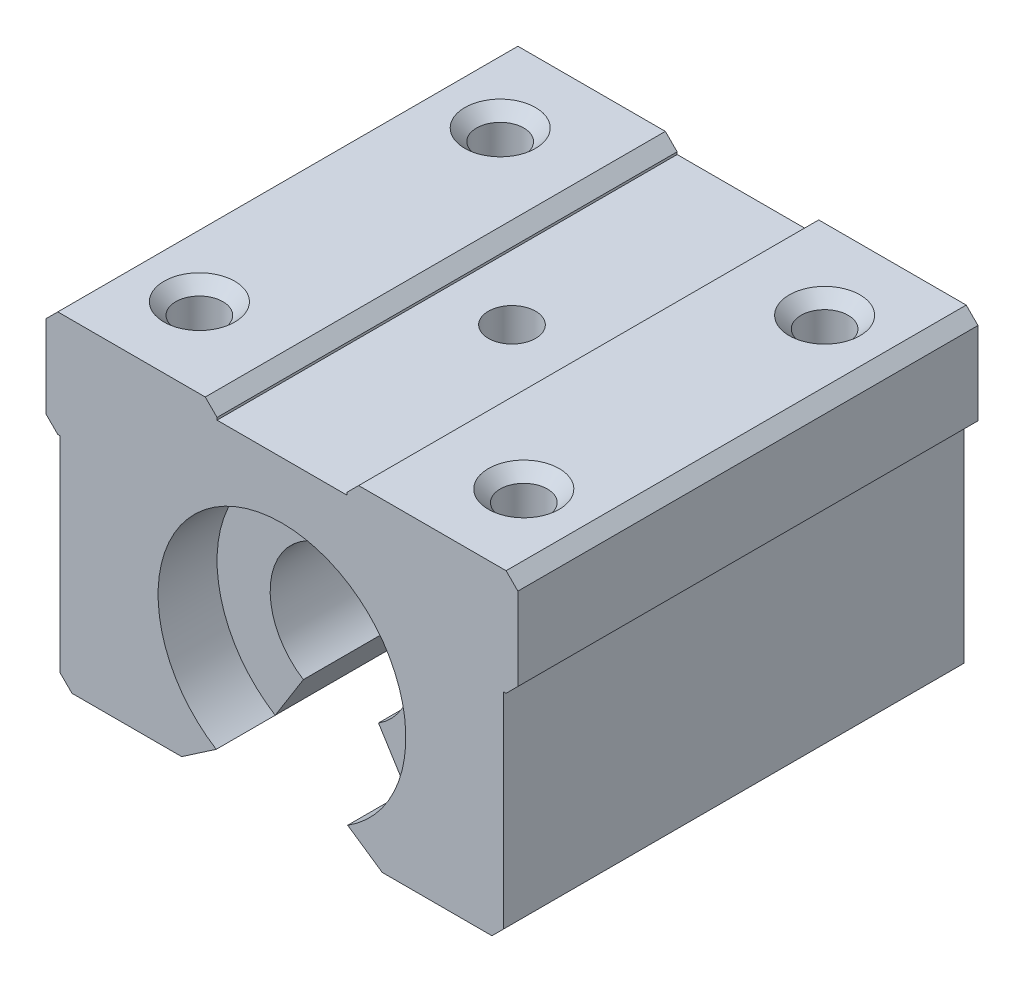
from build123d import *

# Parameters (mm, degrees)
SALIENTE_EXTRUIR1_DEPTH = 39
CORTAR_EXTRUIR1_DEPTH   = 39
SALIENTE_EXTRUIR2_DEPTH = 29
CROQUIS5_R              = 2
CORTAR_EXTRUIR2_DEPTH   = 17
CROQUIS6_R              = 2
CORTAR_EXTRUIR3_DEPTH   = 4
CHAFL_N1_SIZE           = 1


with BuildPart() as part:
    # Croquis1 → Saliente-Extruir1 (new body)
    with BuildSketch(Plane.XY):
        Polygon((-5.5, 13.7), (-5.5, 12.5), (5.5, 12.5), (5.5, 13.7), (20, 13.7), (20, 4.7), (18.8, 4.7), (18.8, -13.7), (-18.8, -13.7), (-18.8, 4.7), (-20, 4.7), (-20, 13.7), align=None)
    extrude(amount=SALIENTE_EXTRUIR1_DEPTH)

    # Croquis2 → Cortar-Extruir1 (cut)
    with BuildSketch(Plane.XY.offset(39)):
        with BuildLine():
            Line((-5.571355311, -11.7), (-8.5, -13.7))
            Line((-8.5, -13.7), (8.5, -13.7))
            Line((8.5, -13.7), (5.571355311, -11.7))
            ThreePointArc((5.571355311, -11.7), (0, 7.7), (-5.571355311, -11.7))
        make_face()
    extrude(amount=-CORTAR_EXTRUIR1_DEPTH, mode=Mode.SUBTRACT)

    # Croquis3 → Saliente-Extruir2 (add)
    with BuildSketch(Plane(origin=(0, 0, 5), x_dir=(-1, 0, 0), z_dir=(0, 0, -1))):
        with BuildLine():
            Line((-3.183631606, -7.885714286), (-5.571355311, -11.7))
            ThreePointArc((-5.571355311, -11.7), (0, 7.7), (5.571355311, -11.7))
            Line((5.571355311, -11.7), (3.183631606, -7.885714286))
            ThreePointArc((3.183631606, -7.885714286), (0, 3.2), (-3.183631606, -7.885714286))
        make_face()
    extrude(amount=-SALIENTE_EXTRUIR2_DEPTH)

    # Croquis5 → Cortar-Extruir2 (cut)
    with BuildSketch(Plane(origin=(0, 13.7, 0), x_dir=(1, 0, 0), z_dir=(0, 1, 0))):
        with Locations((13.75, -32.25)):
            Circle(CROQUIS5_R)
        with Locations((-13.75, -32.25)):
            Circle(CROQUIS5_R)
        with Locations((13.75, -6.75)):
            Circle(CROQUIS5_R)
        with Locations((-13.75, -6.75)):
            Circle(CROQUIS5_R)
    extrude(amount=-CORTAR_EXTRUIR2_DEPTH, mode=Mode.SUBTRACT)

    # Croquis6 → Cortar-Extruir3 (cut)
    with BuildSketch(Plane(origin=(0, 12.5, 0), x_dir=(1, 0, 0), z_dir=(0, 1, 0))):
        with Locations((0, -19.5)):
            Circle(CROQUIS6_R)
    extrude(amount=-CORTAR_EXTRUIR3_DEPTH, mode=Mode.SUBTRACT)

    # Chaflán1
    chafl_n1_edges = [part.edges().sort_by_distance(p)[0] for p in [
        (20, 4.7, 19.5),
        (18.8, -13.7, 19.5),
        (-18.8, -13.7, 19.5),
        (-20, 4.7, 19.5),
        (-20, 13.7, 19.5),
        (-5.5, 13.7, 19.5),
        (5.5, 13.7, 19.5),
        (20, 13.7, 19.5),
        (11.75, 13.7, 32.25),
        (-15.75, 13.7, 32.25),
        (11.75, 13.7, 6.75),
        (-15.75, 13.7, 6.75),
    ]]
    chamfer(chafl_n1_edges, length=CHAFL_N1_SIZE)


solid = part.part
